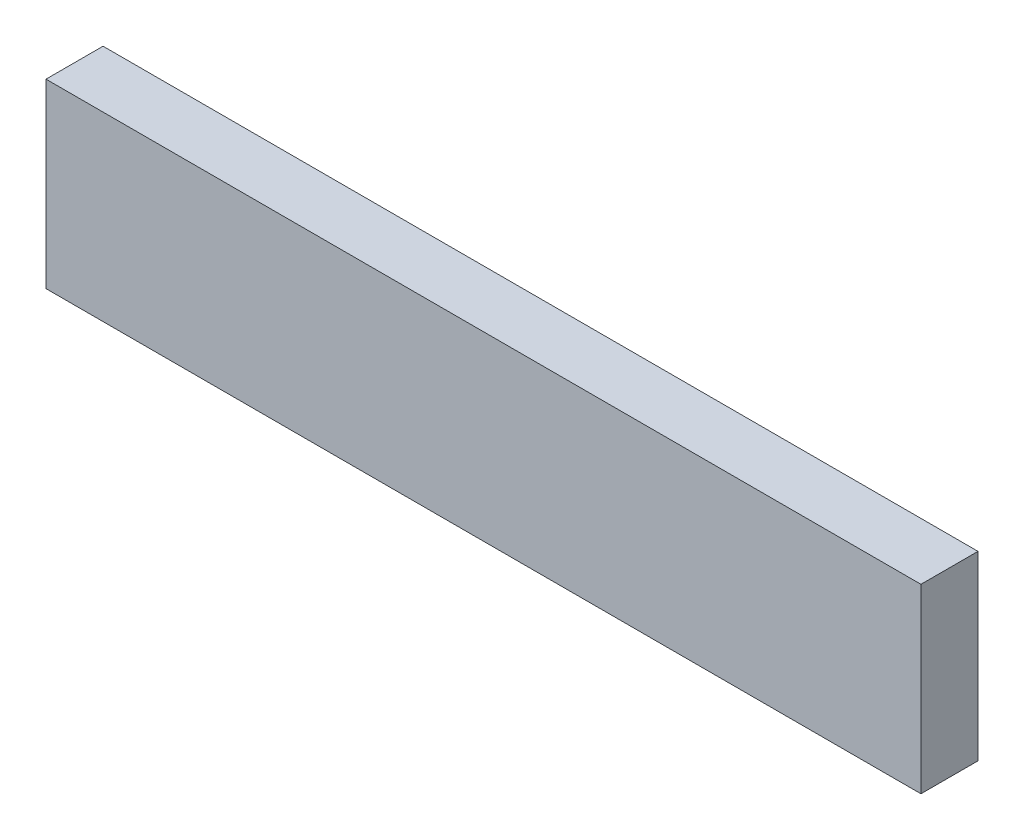
from build123d import *

# Parameters (mm, degrees)
SKETCH1_W           = 146.05
SKETCH1_H           = 30.287570108
BOSS_EXTRUDE1_DEPTH = 9.525


with BuildPart() as part:
    # Sketch1 → Boss-Extrude1 (new body)
    with BuildSketch(Plane.XY):
        Rectangle(SKETCH1_W, SKETCH1_H)
    extrude(amount=BOSS_EXTRUDE1_DEPTH)


solid = part.part
